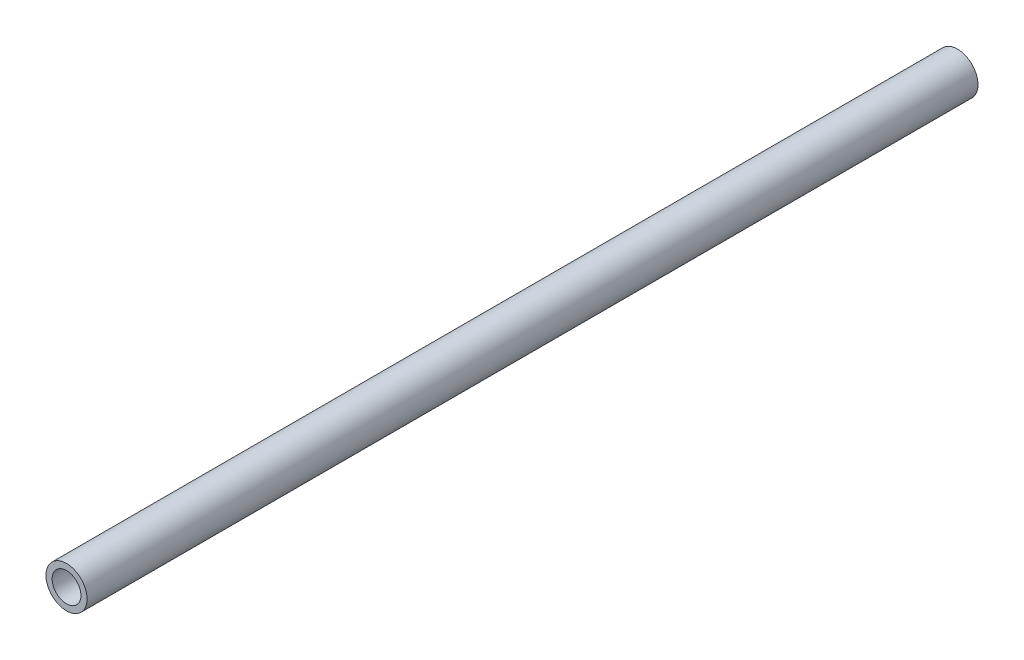
from build123d import *

# Parameters (mm, degrees)
SKETCH1_R           = 3.345
SKETCH1_R_2         = 2.345
BOSS_EXTRUDE1_DEPTH = 145


with BuildPart() as part:
    # Sketch1 → Boss-Extrude1 (new body)
    with BuildSketch(Plane.XY):
        Circle(SKETCH1_R)
        Circle(SKETCH1_R_2, mode=Mode.SUBTRACT)
    extrude(amount=BOSS_EXTRUDE1_DEPTH)


solid = part.part
